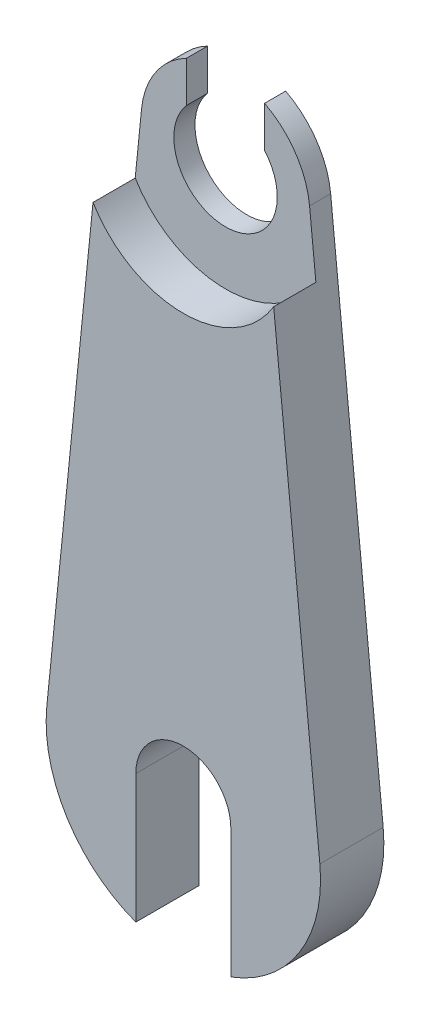
from build123d import *
from build123d.topology import SkipClean

# Parameters (mm, degrees)
SKETCH3_R           = 2.45
BOSS_EXTRUDE1_DEPTH = 1
SKETCH4_W           = 3.7
SKETCH4_H           = 4
CUT_EXTRUDE1_DEPTH  = 1
BOSS_EXTRUDE2_DEPTH = 2
CUT_EXTRUDE2_DEPTH  = 33.30325061


with BuildPart() as part:
    # Sketch3 → Boss-Extrude1 (new body)
    with BuildSketch(Plane.XY):
        with BuildLine():
            Line((3.979949748, 0.4), (6.467418341, -24.35))
            ThreePointArc((6.467418341, -24.35), (0, -31.5), (-6.467418341, -24.35))
            Line((-6.467418341, -24.35), (-3.979949748, 0.4))
            ThreePointArc((-3.979949748, 0.4), (0, 4), (3.979949748, 0.4))
        make_face()
        Circle(SKETCH3_R, mode=Mode.SUBTRACT)
    extrude(amount=BOSS_EXTRUDE1_DEPTH)

    # Sketch4 → Cut-Extrude1 (cut)
    with BuildSketch(Plane.XY.offset(1)):
        with Locations((0, 2)):
            Rectangle(SKETCH4_W, SKETCH4_H)
    extrude(amount=-CUT_EXTRUDE1_DEPTH, mode=Mode.SUBTRACT)

    # Sketch5 → Boss-Extrude2 (add)
    with SkipClean():  # the faces are left unmerged after this step: merging them gives an invalid solid
        with BuildSketch(Plane.XY.offset(1)):
            with BuildLine():
                Line((-4.279949748, -2.584962311), (-6.467418341, -24.35))
                ThreePointArc((-6.467418341, -24.35), (0, -31.5), (6.467418341, -24.35))
                Line((6.467418341, -24.35), (4.279949748, -2.584962311))
                ThreePointArc((4.279949748, -2.584962311), (0, -5), (-4.279949748, -2.584962311))
            make_face()
        extrude(amount=BOSS_EXTRUDE2_DEPTH)

    # Sketch6 → Cut-Extrude2 (cut, through all)
    with SkipClean():  # the faces are left unmerged after this step: merging them gives an invalid solid
        with BuildSketch(Plane.XY.offset(3)):
            with BuildLine():
                Line((2.25, -25), (2.25, -31.5))
                ThreePointArc((2.25, -31.5), (0, -33.75), (-2.25, -31.5))
                Line((-2.25, -31.5), (-2.25, -25))
                ThreePointArc((-2.25, -25), (0, -22.75), (2.25, -25))
            make_face()
        extrude(amount=-CUT_EXTRUDE2_DEPTH, mode=Mode.SUBTRACT)


solid = part.part
